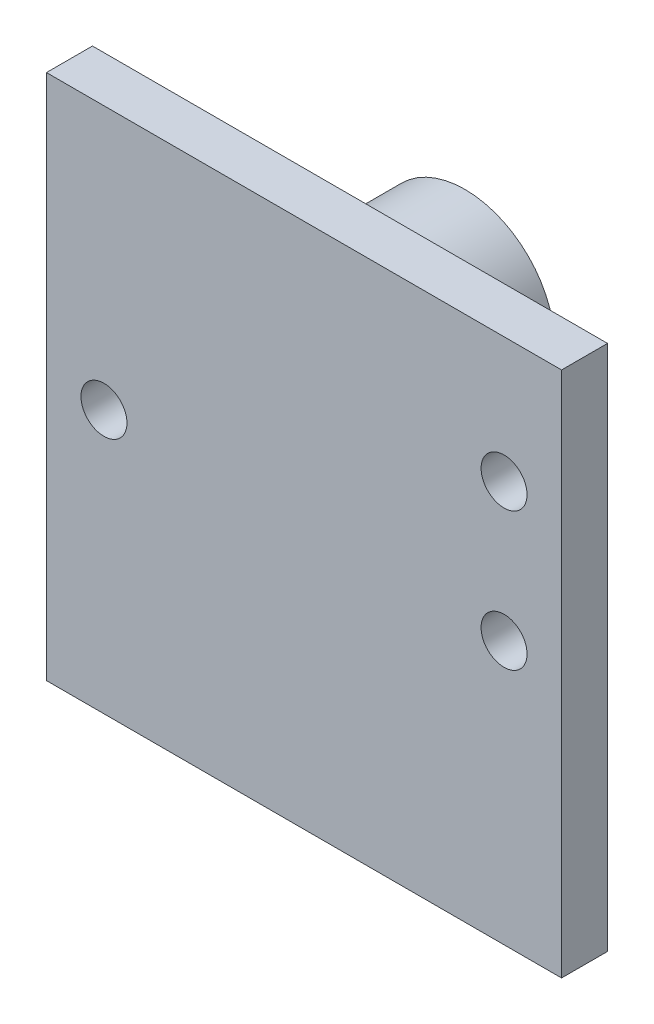
from build123d import *

# Parameters (mm, degrees)
SKETCH1_W           = 22.4
SKETCH1_H           = 22.9
BOSS_EXTRUDE1_DEPTH = 2
SKETCH2_R           = 1
CUT_EXTRUDE1_DEPTH  = 5
SKETCH4_R           = 3.9
BOSS_EXTRUDE3_DEPTH = 5


with BuildPart() as part:
    # Sketch1 → Boss-Extrude1 (new body)
    with BuildSketch(Plane.XY):
        Rectangle(SKETCH1_W, SKETCH1_H)
    extrude(amount=BOSS_EXTRUDE1_DEPTH)

    # Sketch2 → Cut-Extrude1 (cut)
    with BuildSketch(Plane.XY.offset(2)):
        with Locations((-8.7, 0)):
            Circle(SKETCH2_R)
        with Locations((8.7, 0)):
            Circle(SKETCH2_R)
        with Locations((8.7, 6)):
            Circle(SKETCH2_R)
    extrude(amount=-CUT_EXTRUDE1_DEPTH, mode=Mode.SUBTRACT)

    # Sketch4 → Boss-Extrude3 (add)
    with BuildSketch(Plane(origin=(0, 0, 0), x_dir=(-1, 0, 0), z_dir=(0, 0, -1))):
        with Locations((0, 5.25)):
            Circle(SKETCH4_R)
    extrude(amount=BOSS_EXTRUDE3_DEPTH)


solid = part.part
